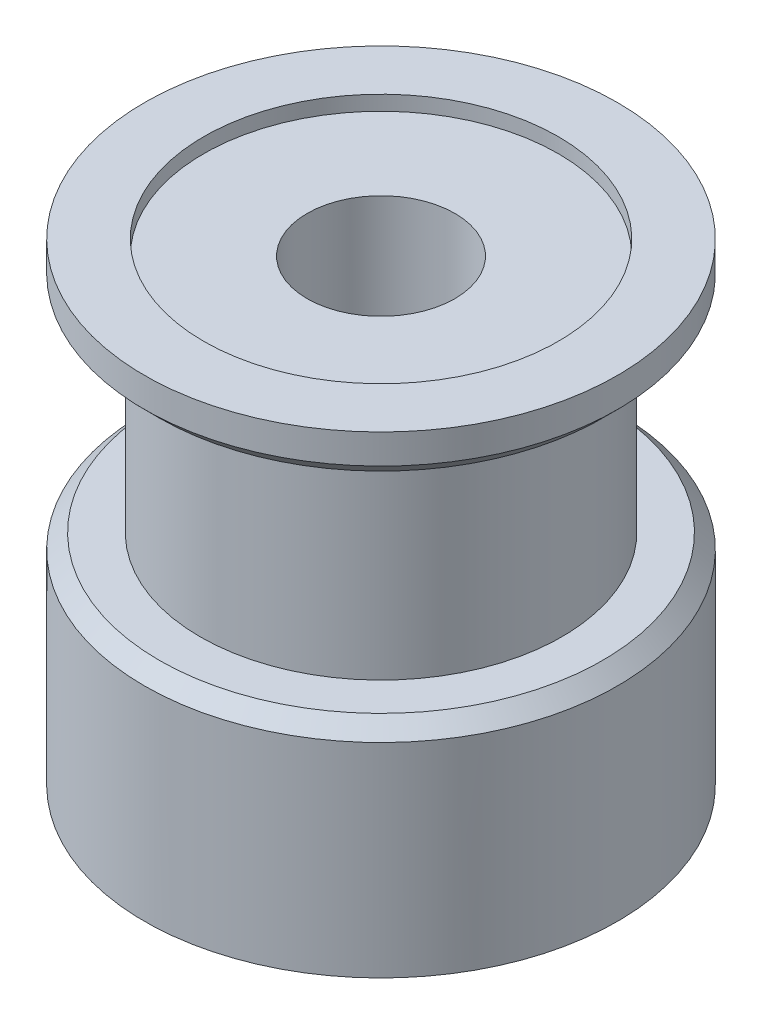
from build123d import *

# Parameters (mm, degrees)
CHAMFER1_SIZE      = 0.5
SKETCH2_R          = 6
CUT_EXTRUDE1_DEPTH = 0.5


with BuildPart() as part:
    # Sketch1 → Revolve1 (revolve)
    with BuildSketch(Plane.XY):
        Polygon((2.5, 0), (2.5, 16), (8, 16), (8, 14.5), (6.12, 14.5), (6.12, 7.4), (8, 7.4), (8, 0), align=None)
    revolve(axis=Axis((0, 0, 0), (0, 1, 0)))

    # Chamfer1
    chamfer1_edges = [part.edges().sort_by_distance(p)[0] for p in [
        (-8, 7.4, 0),
        (-8, 14.5, 0),
    ]]
    chamfer(chamfer1_edges, length=CHAMFER1_SIZE)

    # Sketch2 → Cut-Extrude1 (cut)
    with BuildSketch(Plane(origin=(0, 16, 0), x_dir=(1, 0, 0), z_dir=(0, 1, 0))):
        Circle(SKETCH2_R)
    extrude(amount=-CUT_EXTRUDE1_DEPTH, mode=Mode.SUBTRACT)


solid = part.part
